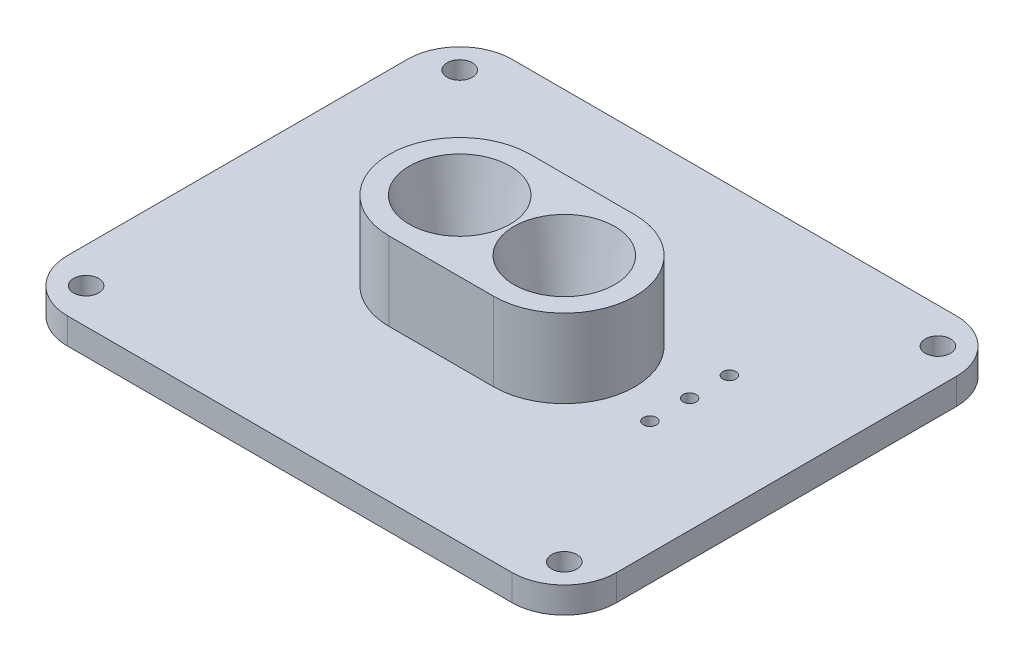
from build123d import *

# Parameters (mm, degrees)
SKETCH1_R           = 3.0607
BOSS_EXTRUDE1_DEPTH = 6.35
SKETCH2_R           = 8.20039
CUT_EXTRUDE1_DEPTH  = 7.35
BOSS_EXTRUDE2_DEPTH = 19.05
SKETCH4_R           = 8.20039
CUT_EXTRUDE2_DEPTH  = 19.05
CUT_EXTRUDE2_TAPER  = -12
SKETCH5_R           = 1.5875
CUT_EXTRUDE3_DEPTH  = 7.35
BOSS_EXTRUDE3_DEPTH = 6.35


with BuildPart() as part:
    # Sketch1 → Boss-Extrude1 (new body)
    with BuildSketch(Plane(origin=(0, 91.487983019, 0), x_dir=(1, 0, 0), z_dir=(0, 1, 0))):
        with BuildLine():
            Line((-19.645108088, -156.928503968), (88.304891912, -156.928503968))
            ThreePointArc((88.304891912, -156.928503968), (95.040084003, -154.138696059), (97.829891912, -147.403503968))
            Line((97.829891912, -147.403503968), (97.829891912, -64.853503968))
            ThreePointArc((97.829891912, -64.853503968), (95.040084003, -58.118311877), (88.304891912, -55.328503968))
            Line((88.304891912, -55.328503968), (-19.645108088, -55.328503968))
            ThreePointArc((-19.645108088, -55.328503968), (-26.380300179, -58.118311877), (-29.170108088, -64.853503968))
            Line((-29.170108088, -64.853503968), (-29.170108088, -147.403503968))
            ThreePointArc((-29.170108088, -147.403503968), (-26.380300179, -154.138696059), (-19.645108088, -156.928503968))
        make_face()
        with Locations((-23.740858088, -151.499253968)):
            Circle(SKETCH1_R, mode=Mode.SUBTRACT)
        with Locations((-23.740858088, -60.757753968)):
            Circle(SKETCH1_R, mode=Mode.SUBTRACT)
        with Locations((92.400641912, -60.757753968)):
            Circle(SKETCH1_R, mode=Mode.SUBTRACT)
        with Locations((92.400641912, -151.499253968)):
            Circle(SKETCH1_R, mode=Mode.SUBTRACT)
    extrude(amount=BOSS_EXTRUDE1_DEPTH)

    # Sketch2 → Cut-Extrude1 (cut, through all)
    with BuildSketch(Plane.XZ.offset(-91.487983019)):
        with Locations((47.029891912, 106.128503968)):
            Circle(SKETCH2_R)
        with Locations((21.629891912, 106.128503968)):
            Circle(SKETCH2_R)
    extrude(amount=-CUT_EXTRUDE1_DEPTH, mode=Mode.SUBTRACT)

    # Sketch3 → Boss-Extrude2 (add)
    with BuildSketch(Plane(origin=(0, 97.837983019, 0), x_dir=(1, 0, 0), z_dir=(0, 1, 0))):
        with BuildLine():
            Line((21.629891912, -88.983503968), (47.029891912, -88.983503968))
            ThreePointArc((47.029891912, -88.983503968), (64.174891912, -106.128503968), (47.029891912, -123.273503968))
            Line((47.029891912, -123.273503968), (21.629891912, -123.273503968))
            ThreePointArc((21.629891912, -123.273503968), (4.484891912, -106.128503968), (21.629891912, -88.983503968))
        make_face()
    extrude(amount=BOSS_EXTRUDE2_DEPTH)

    # Sketch4 → Cut-Extrude2 (cut)
    with BuildSketch(Plane.XZ.offset(-97.837983019)):
        with Locations((21.629891912, 106.128503968)):
            Circle(SKETCH4_R)
        with Locations((47.029891912, 106.128503968)):
            Circle(SKETCH4_R)
    extrude(amount=-CUT_EXTRUDE2_DEPTH, taper=CUT_EXTRUDE2_TAPER, mode=Mode.SUBTRACT)

    # Sketch5 → Cut-Extrude3 (cut, through all)
    with BuildSketch(Plane(origin=(0, 97.837983019, 0), x_dir=(1, 0, 0), z_dir=(0, 1, 0))):
        with Locations((73.223641912, -111.526003968)):
            Circle(SKETCH5_R)
        with Locations((73.223641912, -101.874003968)):
            Circle(SKETCH5_R)
        with Locations((73.223641912, -92.222003968)):
            Circle(SKETCH5_R)
    extrude(amount=-CUT_EXTRUDE3_DEPTH, mode=Mode.SUBTRACT)

    # Sketch6 → Boss-Extrude3 (add)
    with BuildSketch(Plane(origin=(0, 97.837983019, 0), x_dir=(1, 0, 0), z_dir=(0, 1, 0))):
        with BuildLine():
            Line((-32.345108088, -64.853503968), (-32.345108088, -147.403503968))
            ThreePointArc((-32.345108088, -147.403503968), (-28.625364209, -156.383760089), (-19.645108088, -160.103503968))
            Line((-19.645108088, -160.103503968), (88.304891912, -160.103503968))
            ThreePointArc((88.304891912, -160.103503968), (97.285148033, -156.383760089), (101.004891912, -147.403503968))
            Line((101.004891912, -147.403503968), (101.004891912, -64.853503968))
            ThreePointArc((101.004891912, -64.853503968), (97.285148033, -55.873247847), (88.304891912, -52.153503968))
            Line((88.304891912, -52.153503968), (-19.645108088, -52.153503968))
            ThreePointArc((-19.645108088, -52.153503968), (-28.625364209, -55.873247847), (-32.345108088, -64.853503968))
        make_face()
        with BuildLine():
            Line((-19.645108088, -156.928503968), (88.304891912, -156.928503968))
            ThreePointArc((88.304891912, -156.928503968), (95.040084003, -154.138696059), (97.829891912, -147.403503968))
            Line((97.829891912, -147.403503968), (97.829891912, -64.853503968))
            ThreePointArc((97.829891912, -64.853503968), (95.040084003, -58.118311877), (88.304891912, -55.328503968))
            Line((88.304891912, -55.328503968), (-19.645108088, -55.328503968))
            ThreePointArc((-19.645108088, -55.328503968), (-26.380300179, -58.118311877), (-29.170108088, -64.853503968))
            Line((-29.170108088, -64.853503968), (-29.170108088, -147.403503968))
            ThreePointArc((-29.170108088, -147.403503968), (-26.380300179, -154.138696059), (-19.645108088, -156.928503968))
        make_face(mode=Mode.SUBTRACT)
    extrude(amount=-BOSS_EXTRUDE3_DEPTH)


solid = part.part
